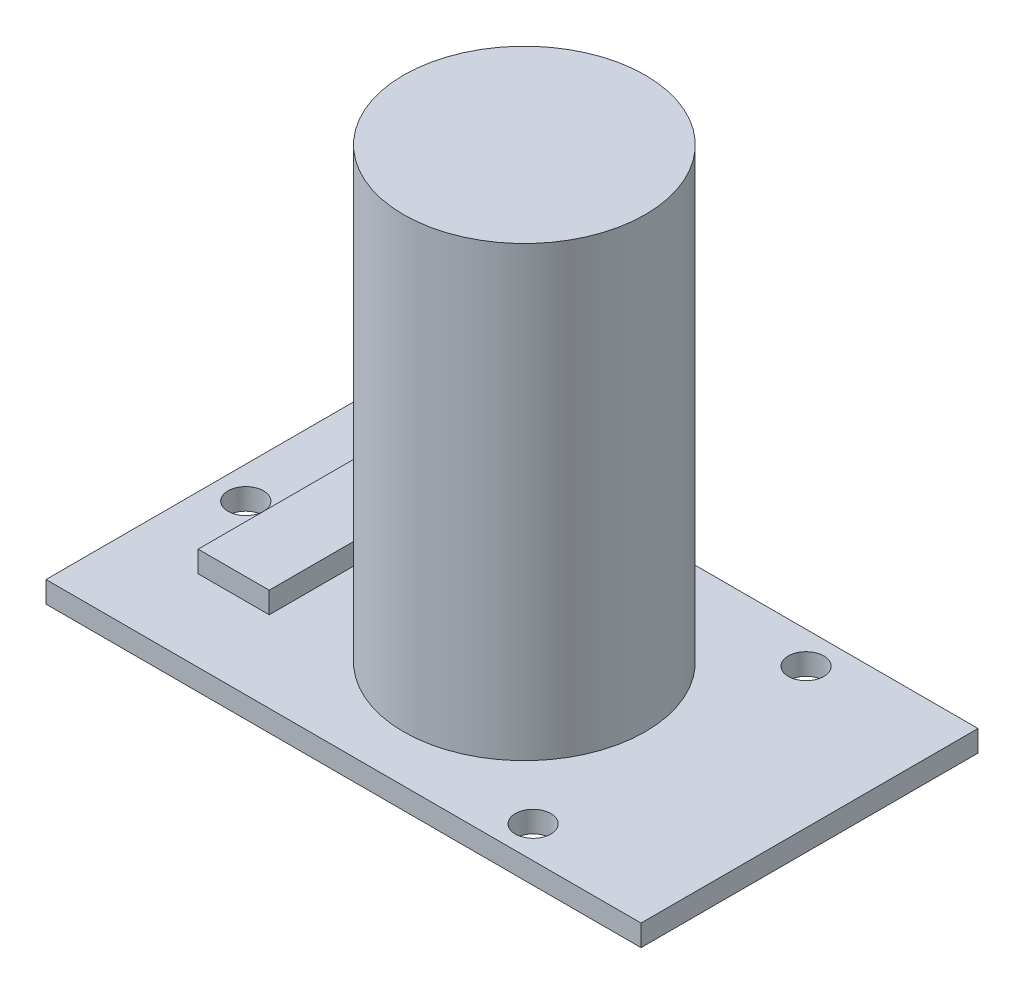
from build123d import *

# Parameters (mm, degrees)
SKETCH2_W           = 41.85
SKETCH2_H           = 23.7
SKETCH2_R           = 1.25
SKETCH2_R_2         = 8.5
BOSS_EXTRUDE1_DEPTH = 1.5
SKETCH2_3_R         = 8.5
BOSS_EXTRUDE2_DEPTH = 33
SKETCH2_6_W         = 5
SKETCH2_6_H         = 12
BOSS_EXTRUDE3_DEPTH = 3


with BuildPart() as part:
    # Sketch2 → Boss-Extrude1 (new body)
    with BuildSketch(Plane(origin=(0, 0, 0), x_dir=(1, 0, 0), z_dir=(0, 1, 0))):
        with Locations((20.925, -11.85)):
            Rectangle(SKETCH2_W, SKETCH2_H)
        with Locations((2.249488742, -11.897962459)):
            Circle(SKETCH2_R, mode=Mode.SUBTRACT)
        with Locations((32.01, -21.45)):
            Circle(SKETCH2_R, mode=Mode.SUBTRACT)
        with Locations((21.85, -11.902335017)):
            Circle(SKETCH2_R_2, mode=Mode.SUBTRACT)
        with Locations((32.01, -2.25)):
            Circle(SKETCH2_R, mode=Mode.SUBTRACT)
    extrude(amount=BOSS_EXTRUDE1_DEPTH)

    # Sketch2_3 → Boss-Extrude2 (add)
    with BuildSketch(Plane(origin=(0, 0, 0), x_dir=(1, 0, 0), z_dir=(0, 1, 0))):
        with Locations((21.85, -11.902335017)):
            Circle(SKETCH2_3_R)
    extrude(amount=BOSS_EXTRUDE2_DEPTH)

    # Sketch2_6 → Boss-Extrude3 (add)
    with BuildSketch(Plane(origin=(0, 0, 0), x_dir=(1, 0, 0), z_dir=(0, 1, 0))):
        with Locations((7.5, -12)):
            Rectangle(SKETCH2_6_W, SKETCH2_6_H)
    extrude(amount=BOSS_EXTRUDE3_DEPTH)


solid = part.part
